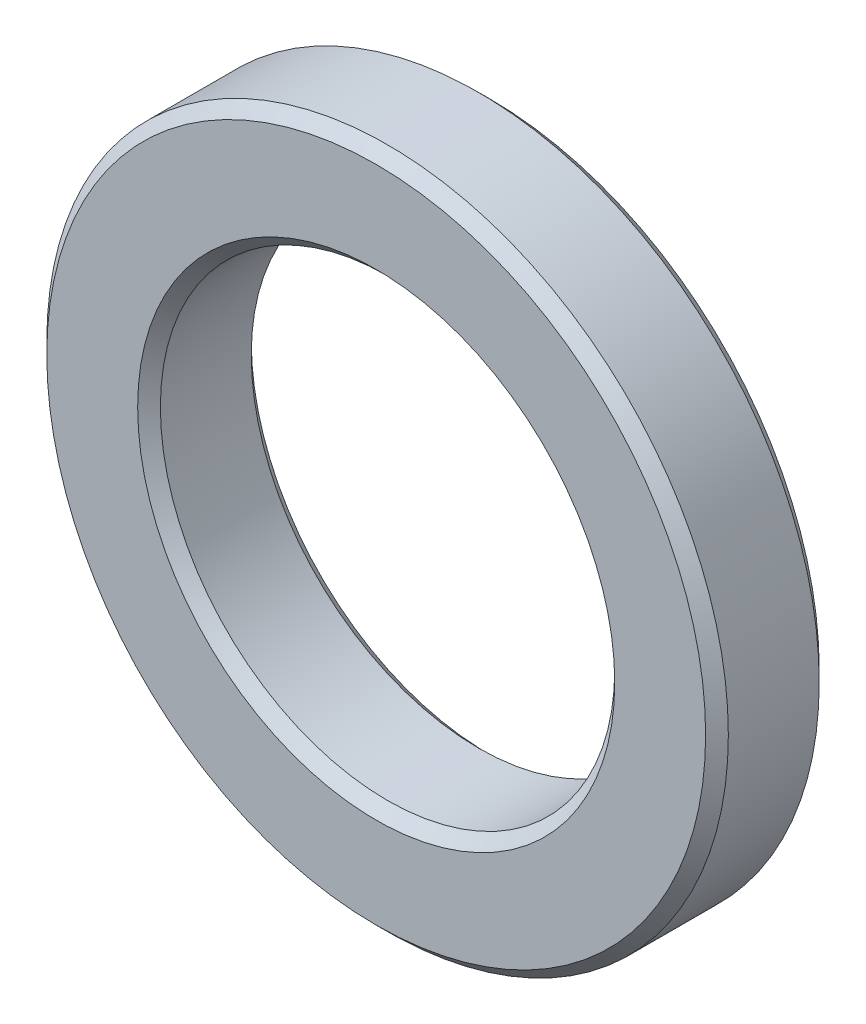
from build123d import *

# Parameters (mm, degrees)
SKETCH_1_R      = 6
SKETCH_1_R_2    = 4
EXTRUDE_1_DEPTH = 2
CHAMFER_1_SIZE  = 0.2


with BuildPart() as part:
    # 草图1 → 拉伸1 (new body)
    with BuildSketch(Plane.XY):
        Circle(SKETCH_1_R)
        Circle(SKETCH_1_R_2, mode=Mode.SUBTRACT)
    extrude(amount=EXTRUDE_1_DEPTH)

    # 倒角1
    chamfer_1_edges = [part.edges().sort_by_distance(p)[0] for p in [
        (-6, 0, 0),
        (-6, 0, 2),
        (-4, 0, 0),
        (-4, 0, 2),
    ]]
    chamfer(chamfer_1_edges, length=CHAMFER_1_SIZE)


solid = part.part
